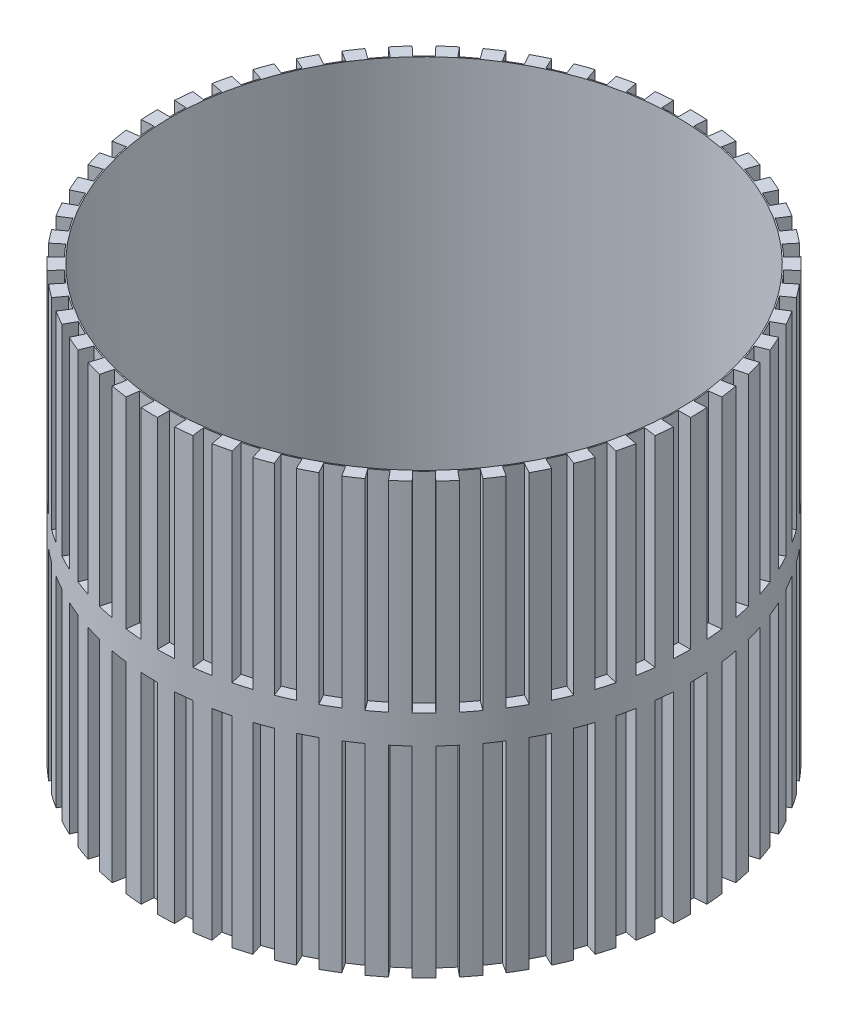
from build123d import *

# Parameters (mm, degrees)
SKETCH_1_R               = 12.89
EXTRUDE_1_DEPTH          = 10.4
CUT_EXTRUDE_3_DEPTH      = 9.71
CUT_EXTRUDE_4_DEPTH      = 9.71
PATTERN_CIRCULAR_4_COUNT = 50
SKETCH_8_R               = 12.25
CUT_EXTRUDE_5_DEPTH      = 20.8


with BuildPart() as part:
    # Эскиз1 → Бобышка-Вытянуть1 (new body, symmetric)
    with BuildSketch(Plane(origin=(0, 0, 0), x_dir=(1, 0, 0), z_dir=(0, 1, 0))):
        Circle(SKETCH_1_R)
    extrude(amount=EXTRUDE_1_DEPTH, both=True)

    # Эскиз4 → Вырез-Вытянуть3 (cut)
    with BuildSketch(Plane(origin=(0, 10.4, 0), x_dir=(1, 0, 0), z_dir=(0, 1, 0))):
        with BuildLine():
            Line((0.77232339, 12.27572876), (0.809369797, 12.864564529))
            ThreePointArc((0.809369797, 12.864564529), (1.213056159, 12.832793724), (1.615545381, 12.7883585))
            Line((1.615545381, 12.7883585), (1.541598773, 12.203010826))
            ThreePointArc((1.541598773, 12.203010826), (1.157532254, 12.245412165), (0.77232339, 12.27572876))
        make_face()
    cut_extrude_3 = extrude(amount=-CUT_EXTRUDE_3_DEPTH, mode=Mode.SUBTRACT)

    # Эскиз6 → Вырез-Вытянуть4 (cut)
    with BuildSketch(Plane.XZ.offset(10.4)):
        with BuildLine():
            Line((0, -12.3), (0, -12.89))
            ThreePointArc((0, -12.89), (0.404884685, -12.883639563), (0.809369797, -12.864564529))
            Line((0.809369797, -12.864564529), (0.77232339, -12.27572876))
            ThreePointArc((0.77232339, -12.27572876), (0.386352337, -12.293930692), (0, -12.3))
        make_face()
    cut_extrude_4 = extrude(amount=-CUT_EXTRUDE_4_DEPTH, mode=Mode.SUBTRACT)

    # Круговой массив4: Вырез-Вытянуть3, Вырез-Вытянуть4 ×50 about axis
    pattern_circular_4_axis = Axis((0, 0, 0), (0, 1, 0))
    for i in range(1, PATTERN_CIRCULAR_4_COUNT):
        add(cut_extrude_3.rotate(pattern_circular_4_axis, i * 360 / PATTERN_CIRCULAR_4_COUNT), mode=Mode.SUBTRACT)
        add(cut_extrude_4.rotate(pattern_circular_4_axis, i * 360 / PATTERN_CIRCULAR_4_COUNT), mode=Mode.SUBTRACT)

    # Эскиз8 → Вырез-Вытянуть5 (cut)
    with BuildSketch(Plane(origin=(0, 10.4, 0), x_dir=(1, 0, 0), z_dir=(0, 1, 0))):
        Circle(SKETCH_8_R)
    extrude(amount=-CUT_EXTRUDE_5_DEPTH, mode=Mode.SUBTRACT)


solid = part.part
